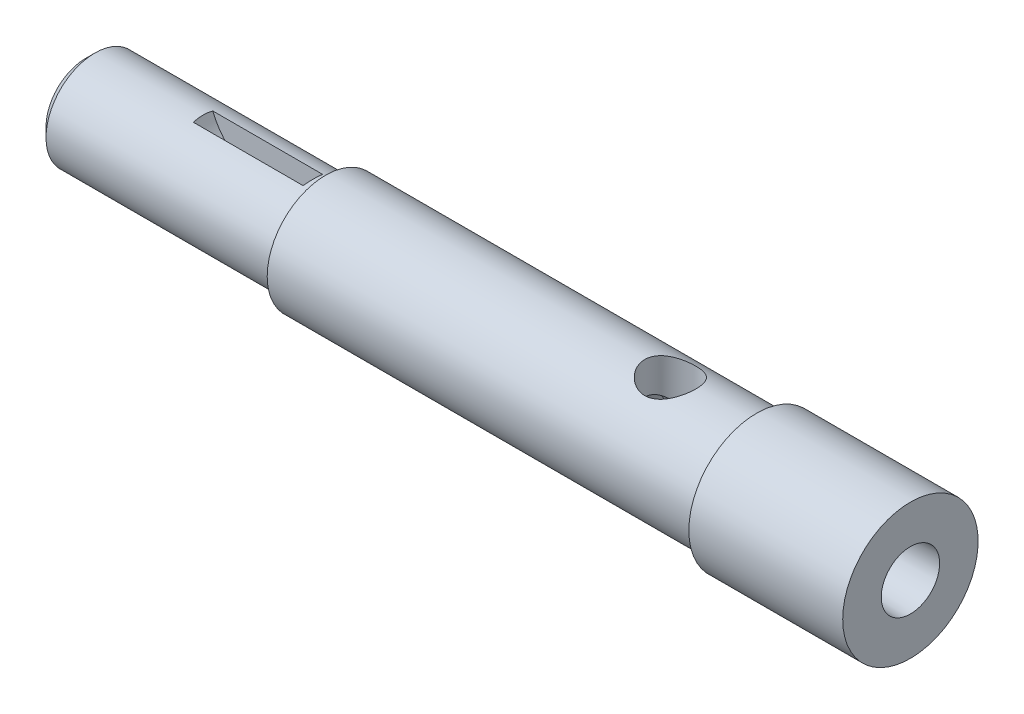
from build123d import *

# Parameters (mm, degrees)
SKETCH4_R          = 4.15
CUT_EXTRUDE1_DEPTH = 15
CHAMFER1_SIZE      = 1.5
CUT_EXTRUDE2_DEPTH = 1.5875


with BuildPart() as part:
    # Sketch1 → Revolve1 (revolve)
    with BuildSketch(Plane.XY):
        Polygon((-67, 0), (67, 0), (67, 11), (42, 11), (42, 9.5), (-28, 9.5), (-28, 7.9375), (-67, 7.9375), align=None)
    revolve(axis=Axis((-84.93546187, 0, 0), (1, 0, 0)))

    # Sketch2 → 1/8 NPT Tapped Hole1 (revolve, cut)
    with BuildSketch(Plane(origin=(67, 0, 0), x_dir=(0, 0, -1), z_dir=(0, 1, 0))):
        Polygon((0, 0), (0, 46.533468714), (4.2164, 44), (4.2164, 6.92404), (4.53740497, 6.92404), (4.74472, 0), align=None)
    revolve(axis=Axis((73.35, 0, 0), (-1, 0, 0)), mode=Mode.SUBTRACT)

    # Sketch4 → Cut-Extrude1 (cut, symmetric)
    with BuildSketch(Plane(origin=(0, 0, 0), x_dir=(1, 0, 0), z_dir=(0, 1, 0))):
        with Locations((28, 0)):
            Circle(SKETCH4_R)
    extrude(amount=CUT_EXTRUDE1_DEPTH, both=True, mode=Mode.SUBTRACT)

    # Chamfer1
    chamfer1_edges = [part.edges().sort_by_distance(p)[0] for p in [
        (-67, -7.9375, 0),
    ]]
    chamfer(chamfer1_edges, length=CHAMFER1_SIZE)

    # Sketch7 → Cut-Extrude2 (cut, symmetric)
    with BuildSketch(Plane.XY):
        with BuildLine():
            Line((-48.391776656, 9.525), (-29.608223344, 9.525))
            ThreePointArc((-29.608223344, 9.525), (-39, 1.5875), (-48.391776656, 9.525))
        make_face()
    extrude(amount=CUT_EXTRUDE2_DEPTH, both=True, mode=Mode.SUBTRACT)


solid = part.part
